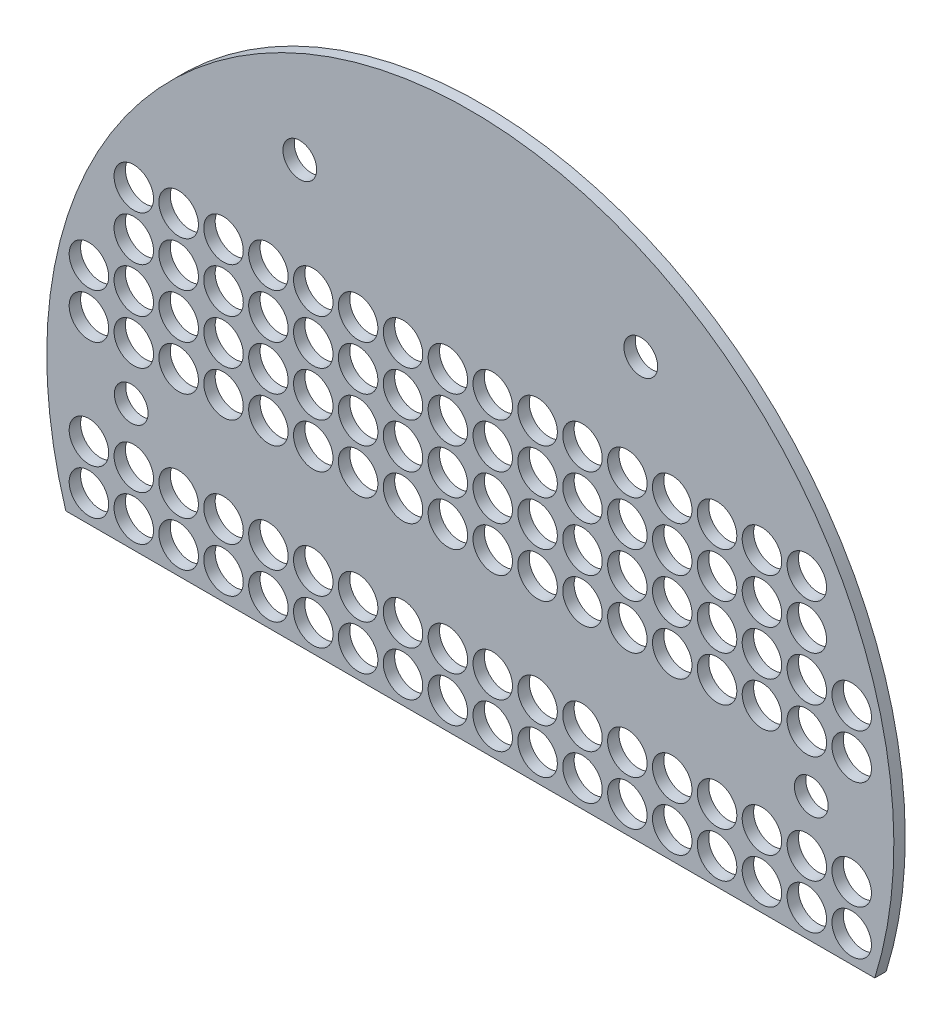
from build123d import *

# Parameters (mm, degrees)
SKETCH1_R           = 11
SKETCH1_R_2         = 9.398
BOSS_EXTRUDE1_DEPTH = 3.175


with BuildPart() as part:
    # Sketch1 → Boss-Extrude1 (new body, symmetric)
    with BuildSketch(Plane.XY):
        with BuildLine():
            Line((-225.920456131, -70.945954707), (224.83906581, -70.945954707))
            ThreePointArc((224.83906581, -70.945954707), (-0.54069516, 235.053783469), (-225.920456131, -70.945954707))
        make_face()
        with Locations((-213.04069516, -55.946216531)):
            Circle(SKETCH1_R, mode=Mode.SUBTRACT)
        with Locations((-188.04069516, -55.946216531)):
            Circle(SKETCH1_R, mode=Mode.SUBTRACT)
        with Locations((-138.04069516, -55.946216531)):
            Circle(SKETCH1_R, mode=Mode.SUBTRACT)
        with Locations((-113.04069516, -55.946216531)):
            Circle(SKETCH1_R, mode=Mode.SUBTRACT)
        with Locations((-88.04069516, -55.946216531)):
            Circle(SKETCH1_R, mode=Mode.SUBTRACT)
        with Locations((-63.04069516, -55.946216531)):
            Circle(SKETCH1_R, mode=Mode.SUBTRACT)
        with Locations((-38.04069516, -55.946216531)):
            Circle(SKETCH1_R, mode=Mode.SUBTRACT)
        with Locations((-13.04069516, -55.946216531)):
            Circle(SKETCH1_R, mode=Mode.SUBTRACT)
        with Locations((211.95930484, -55.946216531)):
            Circle(SKETCH1_R, mode=Mode.SUBTRACT)
        with Locations((211.95930484, -30.946216531)):
            Circle(SKETCH1_R, mode=Mode.SUBTRACT)
        with Locations((186.95930484, -55.946216531)):
            Circle(SKETCH1_R, mode=Mode.SUBTRACT)
        with Locations((186.95930484, -30.946216531)):
            Circle(SKETCH1_R, mode=Mode.SUBTRACT)
        with Locations((161.95930484, -30.946216531)):
            Circle(SKETCH1_R, mode=Mode.SUBTRACT)
        with Locations((161.95930484, -55.946216531)):
            Circle(SKETCH1_R, mode=Mode.SUBTRACT)
        with Locations((136.95930484, -55.946216531)):
            Circle(SKETCH1_R, mode=Mode.SUBTRACT)
        with Locations((136.95930484, -30.946216531)):
            Circle(SKETCH1_R, mode=Mode.SUBTRACT)
        with Locations((111.95930484, -30.946216531)):
            Circle(SKETCH1_R, mode=Mode.SUBTRACT)
        with Locations((111.95930484, -55.946216531)):
            Circle(SKETCH1_R, mode=Mode.SUBTRACT)
        with Locations((86.95930484, -55.946216531)):
            Circle(SKETCH1_R, mode=Mode.SUBTRACT)
        with Locations((86.95930484, -30.946216531)):
            Circle(SKETCH1_R, mode=Mode.SUBTRACT)
        with Locations((61.95930484, -55.946216531)):
            Circle(SKETCH1_R, mode=Mode.SUBTRACT)
        with Locations((61.95930484, -30.946216531)):
            Circle(SKETCH1_R, mode=Mode.SUBTRACT)
        with Locations((36.95930484, -55.946216531)):
            Circle(SKETCH1_R, mode=Mode.SUBTRACT)
        with Locations((36.95930484, -30.946216531)):
            Circle(SKETCH1_R, mode=Mode.SUBTRACT)
        with Locations((11.95930484, -30.946216531)):
            Circle(SKETCH1_R, mode=Mode.SUBTRACT)
        with Locations((-13.04069516, -30.946216531)):
            Circle(SKETCH1_R, mode=Mode.SUBTRACT)
        with Locations((-38.04069516, -30.946216531)):
            Circle(SKETCH1_R, mode=Mode.SUBTRACT)
        with Locations((-63.04069516, -30.946216531)):
            Circle(SKETCH1_R, mode=Mode.SUBTRACT)
        with Locations((-88.04069516, -30.946216531)):
            Circle(SKETCH1_R, mode=Mode.SUBTRACT)
        with Locations((-113.04069516, -30.946216531)):
            Circle(SKETCH1_R, mode=Mode.SUBTRACT)
        with Locations((-138.04069516, -30.946216531)):
            Circle(SKETCH1_R, mode=Mode.SUBTRACT)
        with Locations((-163.04069516, -30.946216531)):
            Circle(SKETCH1_R, mode=Mode.SUBTRACT)
        with Locations((-188.04069516, -30.946216531)):
            Circle(SKETCH1_R, mode=Mode.SUBTRACT)
        with Locations((-213.04069516, -30.946216531)):
            Circle(SKETCH1_R, mode=Mode.SUBTRACT)
        with Locations((94.45930484, 163.598610188)):
            Circle(SKETCH1_R_2, mode=Mode.SUBTRACT)
        with Locations((-95.54069516, 163.598610188)):
            Circle(SKETCH1_R_2, mode=Mode.SUBTRACT)
        with Locations((-63.04069516, 29.053783469)):
            Circle(SKETCH1_R, mode=Mode.SUBTRACT)
        with Locations((-38.04069516, 29.053783469)):
            Circle(SKETCH1_R, mode=Mode.SUBTRACT)
        with Locations((-38.04069516, 54.053783469)):
            Circle(SKETCH1_R, mode=Mode.SUBTRACT)
        with Locations((-63.04069516, 54.053783469)):
            Circle(SKETCH1_R, mode=Mode.SUBTRACT)
        with Locations((-63.04069516, 79.053783469)):
            Circle(SKETCH1_R, mode=Mode.SUBTRACT)
        with Locations((-38.04069516, 79.053783469)):
            Circle(SKETCH1_R, mode=Mode.SUBTRACT)
        with Locations((-13.04069516, 79.053783469)):
            Circle(SKETCH1_R, mode=Mode.SUBTRACT)
        with Locations((-13.04069516, 54.053783469)):
            Circle(SKETCH1_R, mode=Mode.SUBTRACT)
        with Locations((-13.04069516, 29.053783469)):
            Circle(SKETCH1_R, mode=Mode.SUBTRACT)
        with Locations((11.95930484, 29.053783469)):
            Circle(SKETCH1_R, mode=Mode.SUBTRACT)
        with Locations((11.95930484, 54.053783469)):
            Circle(SKETCH1_R, mode=Mode.SUBTRACT)
        with Locations((11.95930484, 79.053783469)):
            Circle(SKETCH1_R, mode=Mode.SUBTRACT)
        with Locations((36.95930484, 79.053783469)):
            Circle(SKETCH1_R, mode=Mode.SUBTRACT)
        with Locations((36.95930484, 54.053783469)):
            Circle(SKETCH1_R, mode=Mode.SUBTRACT)
        with Locations((36.95930484, 29.053783469)):
            Circle(SKETCH1_R, mode=Mode.SUBTRACT)
        with Locations((61.95930484, 29.053783469)):
            Circle(SKETCH1_R, mode=Mode.SUBTRACT)
        with Locations((61.95930484, 79.053783469)):
            Circle(SKETCH1_R, mode=Mode.SUBTRACT)
        with Locations((61.95930484, 54.053783469)):
            Circle(SKETCH1_R, mode=Mode.SUBTRACT)
        with Locations((86.95930484, 54.053783469)):
            Circle(SKETCH1_R, mode=Mode.SUBTRACT)
        with Locations((86.95930484, 29.053783469)):
            Circle(SKETCH1_R, mode=Mode.SUBTRACT)
        with Locations((86.95930484, 79.053783469)):
            Circle(SKETCH1_R, mode=Mode.SUBTRACT)
        with Locations((111.95930484, 79.053783469)):
            Circle(SKETCH1_R, mode=Mode.SUBTRACT)
        with Locations((111.95930484, 54.053783469)):
            Circle(SKETCH1_R, mode=Mode.SUBTRACT)
        with Locations((111.95930484, 29.053783469)):
            Circle(SKETCH1_R, mode=Mode.SUBTRACT)
        with Locations((136.95930484, 29.053783469)):
            Circle(SKETCH1_R, mode=Mode.SUBTRACT)
        with Locations((136.95930484, 54.053783469)):
            Circle(SKETCH1_R, mode=Mode.SUBTRACT)
        with Locations((136.95930484, 79.053783469)):
            Circle(SKETCH1_R, mode=Mode.SUBTRACT)
        with Locations((161.95930484, 79.053783469)):
            Circle(SKETCH1_R, mode=Mode.SUBTRACT)
        with Locations((161.95930484, 54.053783469)):
            Circle(SKETCH1_R, mode=Mode.SUBTRACT)
        with Locations((161.95930484, 29.053783469)):
            Circle(SKETCH1_R, mode=Mode.SUBTRACT)
        with Locations((186.95930484, 29.053783469)):
            Circle(SKETCH1_R, mode=Mode.SUBTRACT)
        with Locations((211.95930484, 29.053783469)):
            Circle(SKETCH1_R, mode=Mode.SUBTRACT)
        with Locations((211.95930484, 54.053783469)):
            Circle(SKETCH1_R, mode=Mode.SUBTRACT)
        with Locations((186.95930484, 54.053783469)):
            Circle(SKETCH1_R, mode=Mode.SUBTRACT)
        with Locations((186.95930484, 79.053783469)):
            Circle(SKETCH1_R, mode=Mode.SUBTRACT)
        with Locations((186.95930484, 104.053783469)):
            Circle(SKETCH1_R, mode=Mode.SUBTRACT)
        with Locations((161.95930484, 104.053783469)):
            Circle(SKETCH1_R, mode=Mode.SUBTRACT)
        with Locations((136.95930484, 104.053783469)):
            Circle(SKETCH1_R, mode=Mode.SUBTRACT)
        with Locations((111.95930484, 104.053783469)):
            Circle(SKETCH1_R, mode=Mode.SUBTRACT)
        with Locations((86.95930484, 104.053783469)):
            Circle(SKETCH1_R, mode=Mode.SUBTRACT)
        with Locations((61.95930484, 104.053783469)):
            Circle(SKETCH1_R, mode=Mode.SUBTRACT)
        with Locations((36.95930484, 104.053783469)):
            Circle(SKETCH1_R, mode=Mode.SUBTRACT)
        with Locations((11.95930484, 104.053783469)):
            Circle(SKETCH1_R, mode=Mode.SUBTRACT)
        with Locations((-13.04069516, 104.053783469)):
            Circle(SKETCH1_R, mode=Mode.SUBTRACT)
        with Locations((-38.04069516, 104.053783469)):
            Circle(SKETCH1_R, mode=Mode.SUBTRACT)
        with Locations((-63.04069516, 104.053783469)):
            Circle(SKETCH1_R, mode=Mode.SUBTRACT)
        with Locations((-88.04069516, 104.053783469)):
            Circle(SKETCH1_R, mode=Mode.SUBTRACT)
        with Locations((-88.04069516, 79.053783469)):
            Circle(SKETCH1_R, mode=Mode.SUBTRACT)
        with Locations((-88.04069516, 54.053783469)):
            Circle(SKETCH1_R, mode=Mode.SUBTRACT)
        with Locations((-88.04069516, 29.053783469)):
            Circle(SKETCH1_R, mode=Mode.SUBTRACT)
        with Locations((-113.04069516, 29.053783469)):
            Circle(SKETCH1_R, mode=Mode.SUBTRACT)
        with Locations((-113.04069516, 54.053783469)):
            Circle(SKETCH1_R, mode=Mode.SUBTRACT)
        with Locations((-113.04069516, 79.053783469)):
            Circle(SKETCH1_R, mode=Mode.SUBTRACT)
        with Locations((-113.04069516, 104.053783469)):
            Circle(SKETCH1_R, mode=Mode.SUBTRACT)
        with Locations((-138.04069516, 104.053783469)):
            Circle(SKETCH1_R, mode=Mode.SUBTRACT)
        with Locations((-138.04069516, 79.053783469)):
            Circle(SKETCH1_R, mode=Mode.SUBTRACT)
        with Locations((-138.04069516, 54.053783469)):
            Circle(SKETCH1_R, mode=Mode.SUBTRACT)
        with Locations((-138.04069516, 29.053783469)):
            Circle(SKETCH1_R, mode=Mode.SUBTRACT)
        with Locations((-163.04069516, 29.053783469)):
            Circle(SKETCH1_R, mode=Mode.SUBTRACT)
        with Locations((-163.04069516, 54.053783469)):
            Circle(SKETCH1_R, mode=Mode.SUBTRACT)
        with Locations((-163.04069516, 104.053783469)):
            Circle(SKETCH1_R, mode=Mode.SUBTRACT)
        with Locations((-188.04069516, 79.053783469)):
            Circle(SKETCH1_R, mode=Mode.SUBTRACT)
        with Locations((-163.04069516, 79.053783469)):
            Circle(SKETCH1_R, mode=Mode.SUBTRACT)
        with Locations((-188.04069516, 104.053783469)):
            Circle(SKETCH1_R, mode=Mode.SUBTRACT)
        with Locations((-188.04069516, 54.053783469)):
            Circle(SKETCH1_R, mode=Mode.SUBTRACT)
        with Locations((-188.04069516, 29.053783469)):
            Circle(SKETCH1_R, mode=Mode.SUBTRACT)
        with Locations((-213.04069516, 29.053783469)):
            Circle(SKETCH1_R, mode=Mode.SUBTRACT)
        with Locations((-213.04069516, 54.053783469)):
            Circle(SKETCH1_R, mode=Mode.SUBTRACT)
        with Locations((-163.04069516, -55.946216531)):
            Circle(SKETCH1_R, mode=Mode.SUBTRACT)
        with Locations((11.95930484, -55.946216531)):
            Circle(SKETCH1_R, mode=Mode.SUBTRACT)
        with Locations((-189.450875853, -0.946216531)):
            Circle(SKETCH1_R_2, mode=Mode.SUBTRACT)
        with Locations((189.450875853, -0.946216531)):
            Circle(SKETCH1_R_2, mode=Mode.SUBTRACT)
    extrude(amount=BOSS_EXTRUDE1_DEPTH, both=True)


solid = part.part
